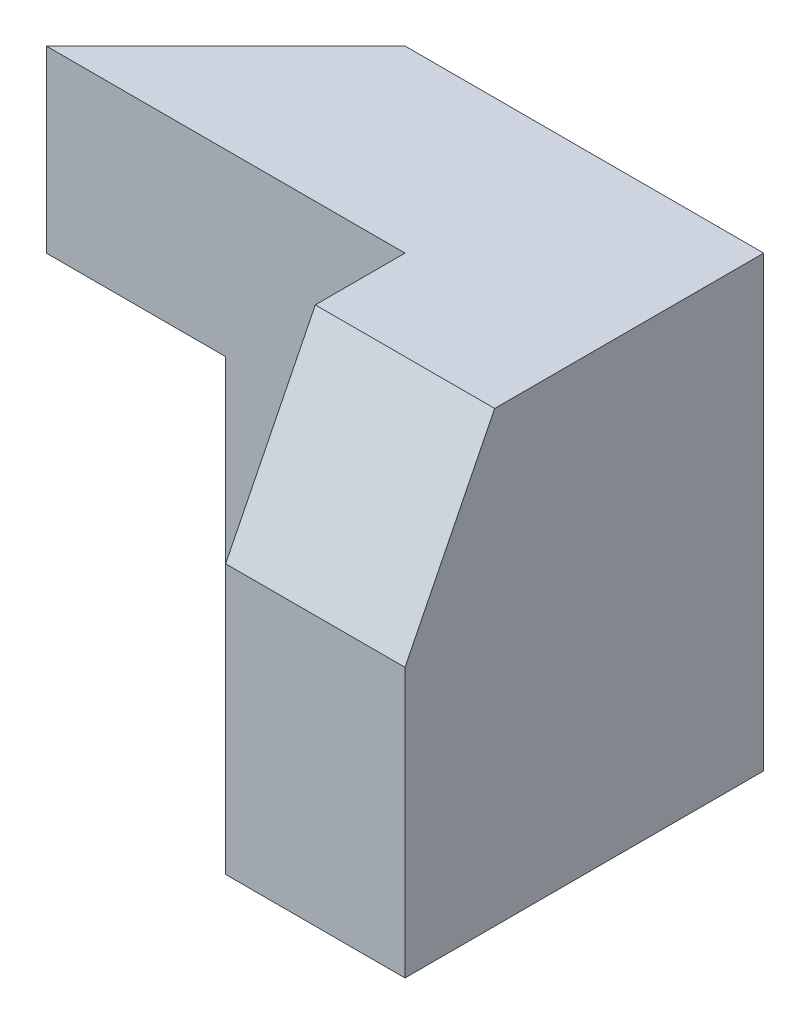
from build123d import *

# Parameters (mm, degrees)
SKETCH1_W           = 30
SKETCH1_H           = 25
BOSS_EXTRUDE1_DEPTH = 20
SKETCH2_W           = 20
SKETCH2_H           = 25
CUT_EXTRUDE1_DEPTH  = 10
CUT_EXTRUDE2_DEPTH  = 20
CUT_EXTRUDE3_DEPTH  = 40
SKETCH5_W           = 20
SKETCH5_H           = 10
CUT_EXTRUDE4_DEPTH  = 20
BOSS_EXTRUDE2_DEPTH = 10


with BuildPart() as part:
    # Sketch1 → Boss-Extrude1 (new body)
    with BuildSketch(Plane.XY):
        with Locations((15, 12.5)):
            Rectangle(SKETCH1_W, SKETCH1_H)
    extrude(amount=BOSS_EXTRUDE1_DEPTH)

    # Sketch2 → Cut-Extrude1 (cut)
    with BuildSketch(Plane.XY.offset(20)):
        with Locations((10, 12.5)):
            Rectangle(SKETCH2_W, SKETCH2_H)
    extrude(amount=-CUT_EXTRUDE1_DEPTH, mode=Mode.SUBTRACT)

    # Sketch3 → Cut-Extrude2 (cut)
    with BuildSketch(Plane.ZY.offset(-20)):
        Polygon((15, 25), (20, 15), (20, 25), align=None)
    extrude(amount=-CUT_EXTRUDE2_DEPTH, mode=Mode.SUBTRACT)

    # Sketch4 → Cut-Extrude3 (cut)
    with BuildSketch(Plane(origin=(0, 25, 0), x_dir=(1, 0, 0), z_dir=(0, 1, 0))):
        Polygon((0, -10), (10, -10), (0, 0), align=None)
    extrude(amount=-CUT_EXTRUDE3_DEPTH, mode=Mode.SUBTRACT)

    # Sketch5 → Cut-Extrude4 (cut)
    with BuildSketch(Plane.ZY.offset(-20)):
        with Locations((0, 20)):
            Rectangle(SKETCH5_W, SKETCH5_H)
    extrude(amount=CUT_EXTRUDE4_DEPTH, mode=Mode.SUBTRACT)

    # Sketch6 → Boss-Extrude2 (add)
    with BuildSketch(Plane(origin=(0, 15, 0), x_dir=(1, 0, 0), z_dir=(0, 1, 0))):
        Polygon((0, -10), (20, -10), (20, 0), (10, 0), align=None)
    extrude(amount=BOSS_EXTRUDE2_DEPTH)


solid = part.part
